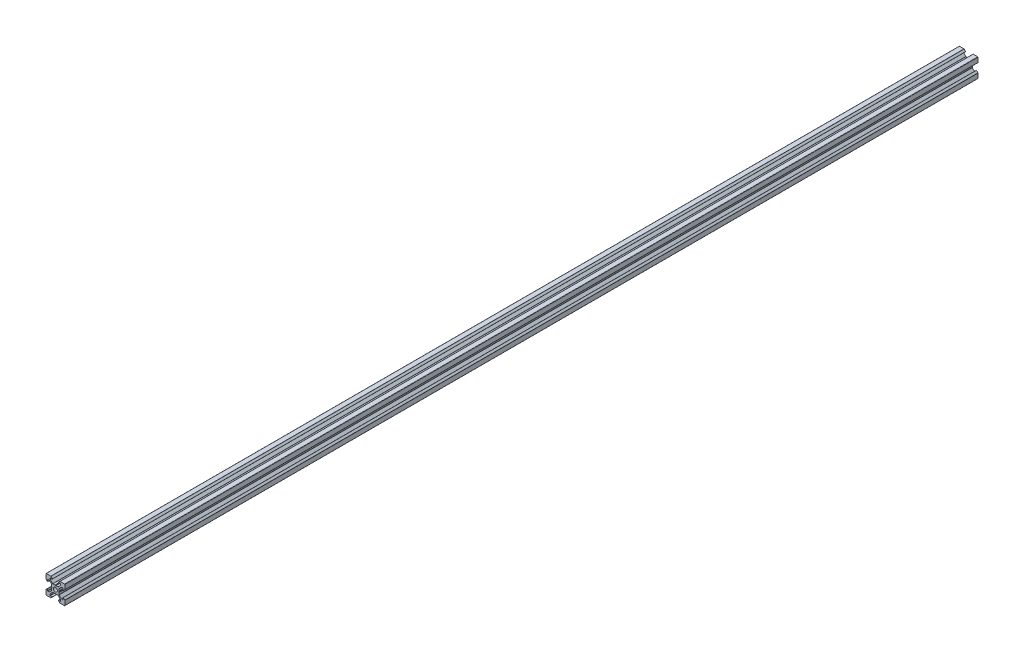
from build123d import *

# Parameters (mm, degrees)
BOSS_EXTRU_1_DEPTH = 970


with BuildPart() as part:
    # Esquisse1 → Boss.-Extru.1 (new body)
    with BuildSketch(Plane.XY):
        with BuildLine():
            Line((18.774857412, -2.895228684), (18.774857412, -4.894568513))
            ThreePointArc((18.774857412, -4.894568513), (18.686989447, -5.106700547), (18.474857412, -5.194568513))
            Line((18.474857412, -5.194568513), (17.259121481, -5.194568513))
            ThreePointArc((17.259121481, -5.194568513), (17.144316451, -5.171732372), (17.046989447, -5.106700547))
            Line((17.046989447, -5.106700547), (14.56338555, -2.62309665))
            ThreePointArc((14.56338555, -2.62309665), (14.498353724, -2.525769645), (14.475517584, -2.410964616))
            Line((14.475517584, -2.410964616), (14.475517584, -0.214843927))
            Line((14.475517584, -0.214843927), (14.175517584, 0.304771316))
            Line((14.175517584, 0.304771316), (14.475517584, 0.824386558))
            Line((14.475517584, 0.824386558), (14.475517584, 3.020507247))
            ThreePointArc((14.475517584, 3.020507247), (14.498353724, 3.135312277), (14.56338555, 3.232639281))
            Line((14.56338555, 3.232639281), (17.046989447, 5.716243178))
            ThreePointArc((17.046989447, 5.716243178), (17.144316451, 5.781275004), (17.259121481, 5.804111144))
            Line((17.259121481, 5.804111144), (18.474857412, 5.804111144))
            ThreePointArc((18.474857412, 5.804111144), (18.686989447, 5.716243178), (18.774857412, 5.504111144))
            Line((18.774857412, 5.504111144), (18.774857412, 3.504771316))
            ThreePointArc((18.774857412, 3.504771316), (18.836589069, 3.412383362), (18.94556809, 3.434060638))
            Line((18.94556809, 3.434060638), (20.486989447, 4.975481994))
            ThreePointArc((20.486989447, 4.975481994), (20.552021272, 5.072808998), (20.574857412, 5.187614028))
            Line((20.574857412, 5.187614028), (20.574857412, 10.004771316))
            ThreePointArc((20.574857412, 10.004771316), (20.486989447, 10.21690335), (20.274857412, 10.304771316))
            Line((20.274857412, 10.304771316), (15.457700125, 10.304771316))
            ThreePointArc((15.457700125, 10.304771316), (15.342895095, 10.281935175), (15.24556809, 10.21690335))
            Line((15.24556809, 10.21690335), (13.704146734, 8.675481994))
            ThreePointArc((13.704146734, 8.675481994), (13.682469459, 8.566502972), (13.774857412, 8.504771316))
            Line((13.774857412, 8.504771316), (15.77419724, 8.504771316))
            ThreePointArc((15.77419724, 8.504771316), (15.986329275, 8.41690335), (16.07419724, 8.204771316))
            Line((16.07419724, 8.204771316), (16.07419724, 6.989035384))
            ThreePointArc((16.07419724, 6.989035384), (16.0513611, 6.874230355), (15.986329275, 6.77690335))
            Line((15.986329275, 6.77690335), (13.502725378, 4.293299453))
            ThreePointArc((13.502725378, 4.293299453), (13.405398373, 4.228267628), (13.290593344, 4.205431487))
            Line((13.290593344, 4.205431487), (11.094472654, 4.205431487))
            Line((11.094472654, 4.205431487), (10.574857412, 3.905431487))
            Line((10.574857412, 3.905431487), (10.05524217, 4.205431487))
            Line((10.05524217, 4.205431487), (7.859121481, 4.205431487))
            ThreePointArc((7.859121481, 4.205431487), (7.744316451, 4.228267628), (7.646989447, 4.293299453))
            Line((7.646989447, 4.293299453), (5.16338555, 6.77690335))
            ThreePointArc((5.16338555, 6.77690335), (5.098353724, 6.874230355), (5.075517584, 6.989035384))
            Line((5.075517584, 6.989035384), (5.075517584, 8.204771316))
            ThreePointArc((5.075517584, 8.204771316), (5.16338555, 8.41690335), (5.375517584, 8.504771316))
            Line((5.375517584, 8.504771316), (7.374857412, 8.504771316))
            ThreePointArc((7.374857412, 8.504771316), (7.467245365, 8.566502972), (7.44556809, 8.675481994))
            Line((7.44556809, 8.675481994), (5.904146734, 10.21690335))
            ThreePointArc((5.904146734, 10.21690335), (5.806819729, 10.281935175), (5.6920147, 10.304771316))
            Line((5.6920147, 10.304771316), (0.874857412, 10.304771316))
            ThreePointArc((0.874857412, 10.304771316), (0.662725378, 10.21690335), (0.574857412, 10.004771316))
            Line((0.574857412, 10.004771316), (0.574857412, 5.187614028))
            ThreePointArc((0.574857412, 5.187614028), (0.597693552, 5.072808998), (0.662725378, 4.975481994))
            Line((0.662725378, 4.975481994), (2.204146734, 3.434060638))
            ThreePointArc((2.204146734, 3.434060638), (2.313125755, 3.412383362), (2.374857412, 3.504771316))
            Line((2.374857412, 3.504771316), (2.374857412, 5.504111144))
            ThreePointArc((2.374857412, 5.504111144), (2.462725378, 5.716243178), (2.674857412, 5.804111144))
            Line((2.674857412, 5.804111144), (3.890593344, 5.804111144))
            ThreePointArc((3.890593344, 5.804111144), (4.005398373, 5.781275004), (4.102725378, 5.716243178))
            Line((4.102725378, 5.716243178), (6.586329275, 3.232639281))
            ThreePointArc((6.586329275, 3.232639281), (6.6513611, 3.135312277), (6.67419724, 3.020507247))
            Line((6.67419724, 3.020507247), (6.67419724, 0.824386558))
            Line((6.67419724, 0.824386558), (6.97419724, 0.304771316))
            Line((6.97419724, 0.304771316), (6.67419724, -0.214843927))
            Line((6.67419724, -0.214843927), (6.67419724, -2.410964616))
            ThreePointArc((6.67419724, -2.410964616), (6.6513611, -2.525769645), (6.586329275, -2.62309665))
            Line((6.586329275, -2.62309665), (4.102725378, -5.106700547))
            ThreePointArc((4.102725378, -5.106700547), (4.005398373, -5.171732372), (3.890593344, -5.194568513))
            Line((3.890593344, -5.194568513), (2.674857412, -5.194568513))
            ThreePointArc((2.674857412, -5.194568513), (2.462725378, -5.106700547), (2.374857412, -4.894568513))
            Line((2.374857412, -4.894568513), (2.374857412, -2.895228684))
            ThreePointArc((2.374857412, -2.895228684), (2.313125755, -2.802840731), (2.204146734, -2.824518006))
            Line((2.204146734, -2.824518006), (0.662725378, -4.365939362))
            ThreePointArc((0.662725378, -4.365939362), (0.597693552, -4.463266367), (0.574857412, -4.578071397))
            Line((0.574857412, -4.578071397), (0.574857412, -9.395228684))
            ThreePointArc((0.574857412, -9.395228684), (0.662725378, -9.607360719), (0.874857412, -9.695228684))
            Line((0.874857412, -9.695228684), (5.6920147, -9.695228684))
            ThreePointArc((5.6920147, -9.695228684), (5.806819729, -9.672392544), (5.904146734, -9.607360719))
            Line((5.904146734, -9.607360719), (7.44556809, -8.065939362))
            ThreePointArc((7.44556809, -8.065939362), (7.467245365, -7.956960341), (7.374857412, -7.895228684))
            Line((7.374857412, -7.895228684), (5.375517584, -7.895228684))
            ThreePointArc((5.375517584, -7.895228684), (5.16338555, -7.807360719), (5.075517584, -7.595228684))
            Line((5.075517584, -7.595228684), (5.075517584, -6.379492753))
            ThreePointArc((5.075517584, -6.379492753), (5.098353724, -6.264687723), (5.16338555, -6.167360719))
            Line((5.16338555, -6.167360719), (7.646989447, -3.683756822))
            ThreePointArc((7.646989447, -3.683756822), (7.744316451, -3.618724996), (7.859121481, -3.595888856))
            Line((7.859121481, -3.595888856), (10.05524217, -3.595888856))
            Line((10.05524217, -3.595888856), (10.574857412, -3.295888856))
            Line((10.574857412, -3.295888856), (11.094472654, -3.595888856))
            Line((11.094472654, -3.595888856), (13.290593344, -3.595888856))
            ThreePointArc((13.290593344, -3.595888856), (13.405398373, -3.618724996), (13.502725378, -3.683756822))
            Line((13.502725378, -3.683756822), (15.986329275, -6.167360719))
            ThreePointArc((15.986329275, -6.167360719), (16.0513611, -6.264687723), (16.07419724, -6.379492753))
            Line((16.07419724, -6.379492753), (16.07419724, -7.595228684))
            ThreePointArc((16.07419724, -7.595228684), (15.986329275, -7.807360719), (15.77419724, -7.895228684))
            Line((15.77419724, -7.895228684), (13.774857412, -7.895228684))
            ThreePointArc((13.774857412, -7.895228684), (13.682469459, -7.956960341), (13.704146734, -8.065939362))
            Line((13.704146734, -8.065939362), (15.24556809, -9.607360719))
            ThreePointArc((15.24556809, -9.607360719), (15.342895095, -9.672392544), (15.457700125, -9.695228684))
            Line((15.457700125, -9.695228684), (20.274857412, -9.695228684))
            ThreePointArc((20.274857412, -9.695228684), (20.486989447, -9.607360719), (20.574857412, -9.395228684))
            Line((20.574857412, -9.395228684), (20.574857412, -4.578071397))
            ThreePointArc((20.574857412, -4.578071397), (20.552021272, -4.463266367), (20.486989447, -4.365939362))
            Line((20.486989447, -4.365939362), (18.94556809, -2.824518006))
            ThreePointArc((18.94556809, -2.824518006), (18.836589069, -2.802840731), (18.774857412, -2.895228684))
        make_face()
        with BuildLine():
            ThreePointArc((10.574857412, -1.795228684), (12.059781653, -1.180152925), (12.674857412, 0.304771316))
            ThreePointArc((12.674857412, 0.304771316), (12.059781653, 1.789695556), (10.574857412, 2.404771316))
            ThreePointArc((10.574857412, 2.404771316), (9.089933172, 1.789695556), (8.474857412, 0.304771316))
            ThreePointArc((8.474857412, 0.304771316), (9.089933172, -1.180152925), (10.574857412, -1.795228684))
        make_face(mode=Mode.SUBTRACT)
    extrude(amount=BOSS_EXTRU_1_DEPTH)


solid = part.part
